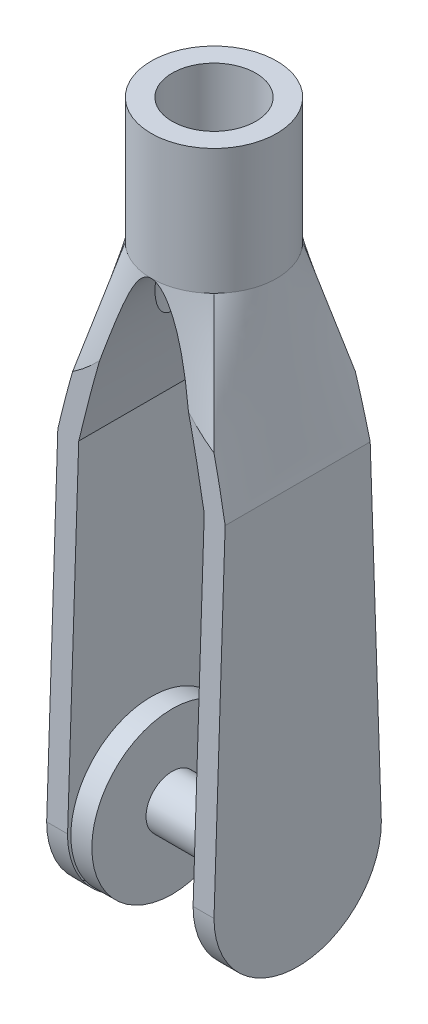
from build123d import *

# Parameters (mm, degrees)
SKETCH6_W               = 4
SKETCH6_H               = 4
SKETCH8_R               = 1.5
BOSS_EXTRUDE4_DEPTH     = 3
SKETCH9_W               = 4
SKETCH9_H               = 4
BOSS_EXTRUDE5_DEPTH     = 10
CUT_EXTRUDE1_DEPTH      = 11.954451205
CUT_EXTRUDE1_DEPTH_BACK = 11.954451205
CUT_EXTRUDE_THIN1_DEPTH = 10
SKETCH12_R              = 0.625
CUT_EXTRUDE2_DEPTH      = 11.954451205
CUT_EXTRUDE2_DEPTH_BACK = 11.954451205
SKETCH13_R              = 1
CUT_EXTRUDE3_DEPTH      = 18.233687963
CUT_EXTRUDE3_DEPTH_BACK = 18.233687963
SKETCH14_R              = 1.920216589
BOSS_EXTRUDE6_DEPTH     = 0.5
SKETCH15_R              = 0.625
BOSS_EXTRUDE7_DEPTH     = 3


with BuildPart() as part:
    # Sketch7 for Loft1 → Loft1 section 0
    with BuildSketch(Plane(origin=(0, 4, 0), x_dir=(1, 0, 0), z_dir=(0, 1, 0))):
        with BuildLine():
            # circular arc as an exact rational Bezier (weights 1, cos(half-angle), 1)
            Bezier((-1.060660172, -1.060660172), (0, -2.121320343), (1.060660172, -1.060660172), weights=[1, 0.707106782, 1])
            Bezier((1.060660172, -1.060660172), (2.121320343, 0), (1.060660172, 1.060660172), weights=[1, 0.707106782, 1])
            Bezier((1.060660172, 1.060660172), (0, 2.121320343), (-1.060660172, 1.060660172), weights=[1, 0.707106782, 1])
            Bezier((-1.060660172, 1.060660172), (-2.121320343, 0), (-1.060660172, -1.060660172), weights=[1, 0.707106782, 1])
        make_face()
    # Sketch6 → Loft1 section 1
    with BuildSketch(Plane(origin=(0, 0, 0), x_dir=(1, 0, 0), z_dir=(0, 1, 0))):
        Rectangle(SKETCH6_W, SKETCH6_H)
    loft()

    # Sketch8 → Boss-Extrude4 (add)
    with BuildSketch(Plane(origin=(0, 4, 0), x_dir=(1, 0, 0), z_dir=(0, 1, 0))):
        with Locations(Location((0, 0, 0), (0, 0, 45))):
            Circle(SKETCH8_R)
    extrude(amount=BOSS_EXTRUDE4_DEPTH)

    # Sketch9 → Boss-Extrude5 (add)
    with BuildSketch(Plane.XZ):
        Rectangle(SKETCH9_W, SKETCH9_H)
    extrude(amount=BOSS_EXTRUDE5_DEPTH)

    # Sketch10 → Cut-Extrude1 (cut, two sides)
    with BuildSketch(Plane(origin=(0, 0, -2), x_dir=(-1, 0, 0), z_dir=(0, 0, -1))) as cut_extrude1_sk:
        with BuildLine():
            Line((-1.5, -10), (-1.5, 0))
            add(Edge.make_bspline(
                [(-1.5, 0), (0, 7), (1.5, 0)],
                knots=[0, 0, 0, 1, 1, 1], degree=2, weights=[1, 1.333333333, 1]))
            Line((1.5, 0), (1.5, -10))
            Line((1.5, -10), (-1.5, -10))
        make_face()
    extrude(amount=CUT_EXTRUDE1_DEPTH, mode=Mode.SUBTRACT)
    extrude(cut_extrude1_sk.sketch, amount=-CUT_EXTRUDE1_DEPTH_BACK, mode=Mode.SUBTRACT)

    # Sketch11 → Cut-Extrude-Thin1 (cut)
    with BuildSketch(Plane(origin=(2, 0, 0), x_dir=(0, 0, -1), z_dir=(1, 0, 0))):
        with BuildLine():
            Line((11.997667212, -7.763395965), (11.17222068, 17))
            Line((11.17222068, 17), (-11.17222068, 17))
            Line((-11.17222068, 17), (-11.997667212, -7.763395965))
            ThreePointArc((-11.997667212, -7.763395965), (0, -20), (11.997667212, -7.763395965))
        make_face()
        with BuildLine():
            Line((2, -8), (1.5, 7))
            Line((1.5, 7), (-1.5, 7))
            Line((-1.5, 7), (-2, -8))
            ThreePointArc((-2, -8), (0, -10), (2, -8))
        make_face(mode=Mode.SUBTRACT)
    extrude(amount=-CUT_EXTRUDE_THIN1_DEPTH, mode=Mode.SUBTRACT)

    # Sketch12 → Cut-Extrude2 (cut, two sides)
    with BuildSketch(Plane(origin=(2, 0, 0), x_dir=(0, 0, -1), z_dir=(1, 0, 0))) as cut_extrude2_sk:
        with Locations((0, -8.079783411)):
            Circle(SKETCH12_R)
    extrude(amount=CUT_EXTRUDE2_DEPTH, mode=Mode.SUBTRACT)
    extrude(cut_extrude2_sk.sketch, amount=-CUT_EXTRUDE2_DEPTH_BACK, mode=Mode.SUBTRACT)

    # Sketch13 → Cut-Extrude3 (cut, two sides)
    with BuildSketch(Plane(origin=(0, 7, 0), x_dir=(1, 0, 0), z_dir=(0, 1, 0))) as cut_extrude3_sk:
        with Locations(Location((0, 0, 0), (0, 0, 270))):
            Circle(SKETCH13_R)
    extrude(amount=CUT_EXTRUDE3_DEPTH, mode=Mode.SUBTRACT)
    extrude(cut_extrude3_sk.sketch, amount=-CUT_EXTRUDE3_DEPTH_BACK, mode=Mode.SUBTRACT)

    # Sketch14 → Boss-Extrude6 (add)
    with BuildSketch(Plane(origin=(-1.5, 0, 0), x_dir=(0, 0, -1), z_dir=(1, 0, 0))):
        with Locations(Location((0, -8.079783411, 0), (0, 0, 269.997072333))):
            Circle(SKETCH14_R)
    extrude(amount=BOSS_EXTRUDE6_DEPTH)

    # Sketch15 → Boss-Extrude7 (add)
    with BuildSketch(Plane(origin=(-1, 0, 0), x_dir=(0, 0, -1), z_dir=(1, 0, 0))):
        with Locations((0, -8.079783411)):
            Circle(SKETCH15_R)
    extrude(amount=BOSS_EXTRUDE7_DEPTH)


solid = part.part
